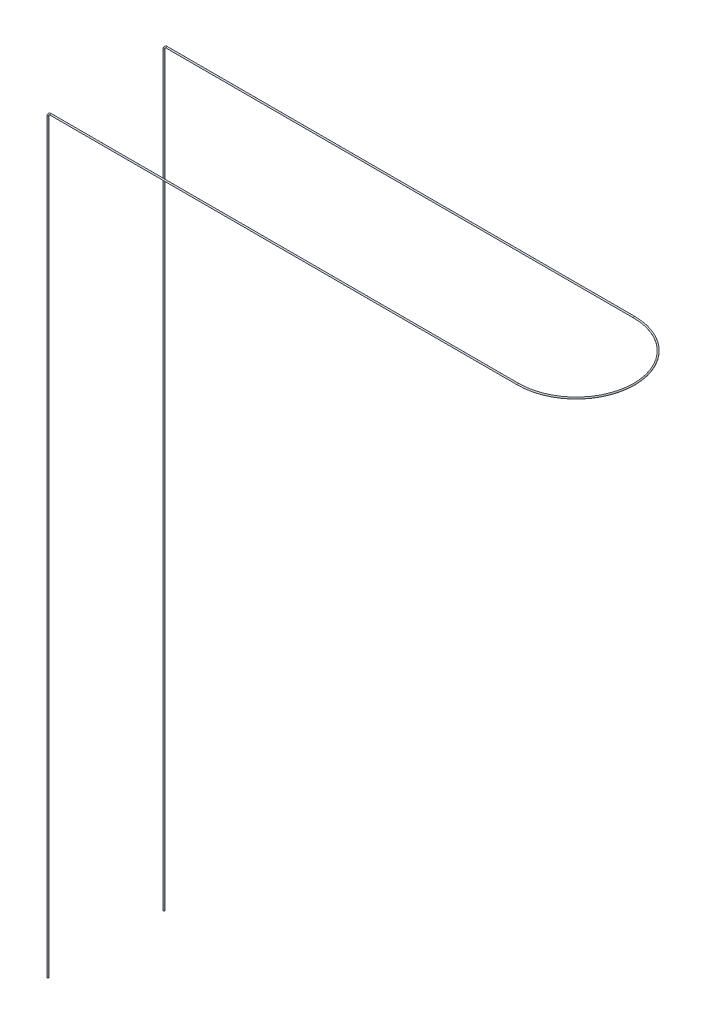
from build123d import *

# Parameters (mm, degrees)
BALAYAGE1_PROFILE_R = 0.25


with BuildPart() as part:
    # Balayage1: sweep along a curve in space
    with BuildLine() as balayage1_path:
        Line((0, 0, 0), (0, 257, 0))
        ThreePointArc((1, 258, 0), (0.292893219, 257.707106781, 0), (0, 257, 0))
        Line((1, 258, 0), (162, 258, 0))
        ThreePointArc((162, 258, -40), (182, 258, -20), (162, 258, 0))
        Line((162, 258, -40), (1, 258, -40))
        ThreePointArc((1, 258, -40), (0.292893219, 257.707106781, -40), (0, 257, -40))
        Line((0, 257, -40), (0, 0, -40))
    # Balayage1 profile (on start of the path) → Balayage1 (sweep)
    with BuildSketch(Plane(origin=(0, 0, 0), x_dir=(1, 0, 0), z_dir=(0, 1, 0))):
        Circle(BALAYAGE1_PROFILE_R)
    sweep(path=balayage1_path.line)


solid = part.part
